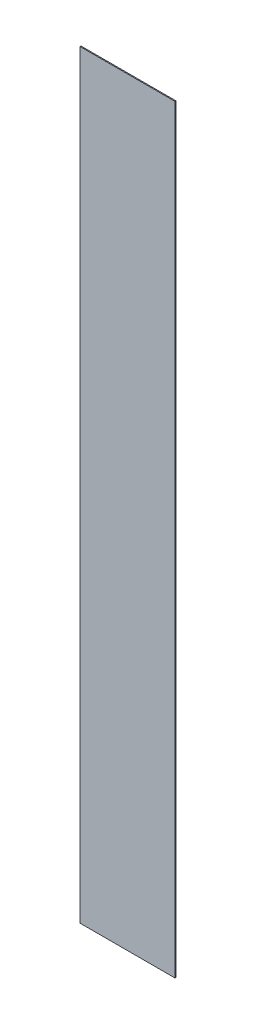
from build123d import *

# Parameters (mm, degrees)
SKETCH1_W           = 50.8
SKETCH1_H           = 406.4
BOSS_EXTRUDE1_DEPTH = 0.508


with BuildPart() as part:
    # Sketch1 → Boss-Extrude1 (new body)
    with BuildSketch(Plane.XY):
        with Locations((25.4, 203.2)):
            Rectangle(SKETCH1_W, SKETCH1_H)
    extrude(amount=BOSS_EXTRUDE1_DEPTH)


solid = part.part
